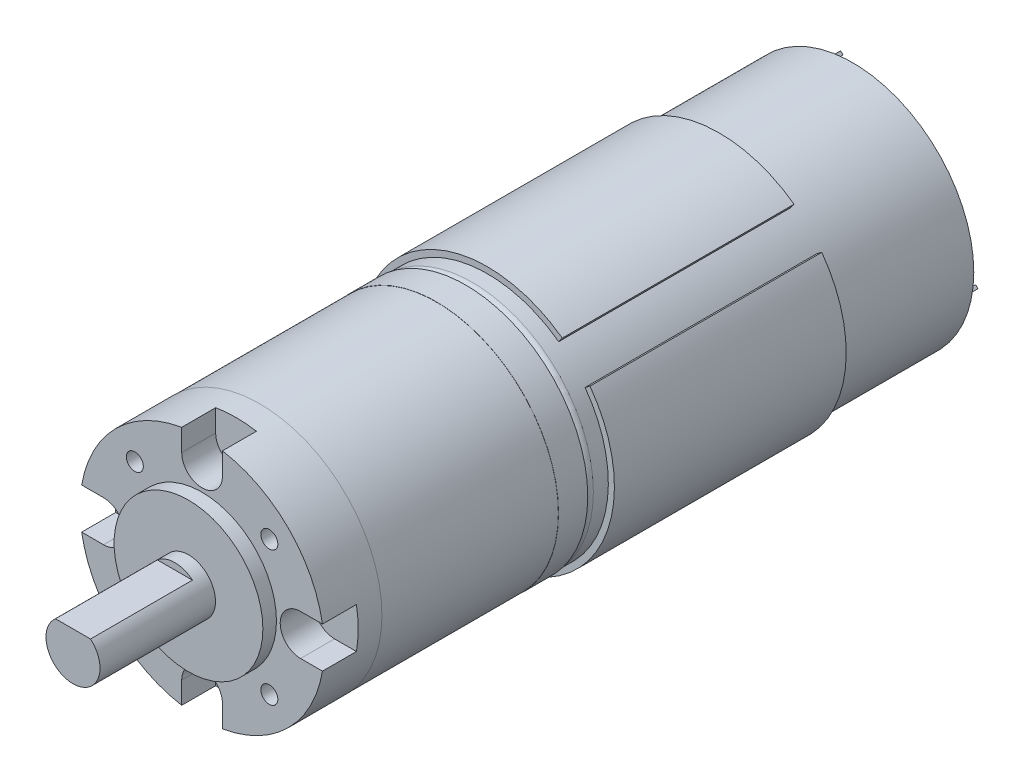
from build123d import *

# Parameters (mm, degrees)
SKETCH1_R                      = 17.975
BOSS_EXTRUDE1_DEPTH            = 8.5
CUT_EXTRUDE1_DEPTH             = 5
SKETCH3_R                      = 10.95
BOSS_EXTRUDE2_DEPTH            = 2
SKETCH4_R                      = 3.975
BOSS_EXTRUDE3_DEPTH            = 17
SKETCH5_W                      = 5.157518784
SKETCH5_H                      = 0.95
CUT_EXTRUDE2_DEPTH             = 15
SKETCH7_W                      = 1.25
SKETCH7_H                      = 8.5
M3X0_5_TAPPED_HOLE1_AT_2_COUNT = 2
M3X0_5_TAPPED_HOLE1_AT_2_PITCH = 19.798989873
M3X0_5_TAPPED_HOLE1_AT_3_COUNT = 2
M3X0_5_TAPPED_HOLE1_AT_3_PITCH = 28
M3X0_5_TAPPED_HOLE1_AT_4_COUNT = 2
M3X0_5_TAPPED_HOLE1_AT_4_PITCH = 19.798989873
SKETCH8_R                      = 17.95
BOSS_EXTRUDE4_DEPTH            = 26
SKETCH9_R                      = 17.975
BOSS_EXTRUDE5_DEPTH            = 4.3
SKETCH10_R                     = 17.8
BOSS_EXTRUDE6_DEPTH            = 57
FILLET1_R                      = 1
SKETCH11_R                     = 5.375
BOSS_EXTRUDE7_DEPTH            = 2.95
BOSS_EXTRUDE8_DEPTH            = 7
BOSS_EXTRUDE8_2_DEPTH          = 7
BOSS_EXTRUDE9_DEPTH            = 34.12


with BuildPart() as part:
    # Sketch1 → Boss-Extrude1 (new body)
    with BuildSketch(Plane.XY):
        Circle(SKETCH1_R)
    extrude(amount=BOSS_EXTRUDE1_DEPTH)

    # Sketch2 → Cut-Extrude1 (cut)
    with BuildSketch(Plane.XY.offset(8.5)):
        with BuildLine():
            Line((-14.5, -3), (-24.5, -3))
            ThreePointArc((-24.5, -3), (-27.5, 0), (-24.5, 3))
            Line((-24.5, 3), (-14.5, 3))
            ThreePointArc((-14.5, 3), (-11.5, 0), (-14.5, -3))
        make_face()
        with BuildLine():
            Line((14.5, -3), (24.5, -3))
            ThreePointArc((24.5, -3), (27.5, 0), (24.5, 3))
            Line((24.5, 3), (14.5, 3))
            ThreePointArc((14.5, 3), (11.5, 0), (14.5, -3))
        make_face()
        with BuildLine():
            Line((-3, 14.5), (-3, 24.5))
            ThreePointArc((-3, 24.5), (0, 27.5), (3, 24.5))
            Line((3, 24.5), (3, 14.5))
            ThreePointArc((3, 14.5), (0, 11.5), (-3, 14.5))
        make_face()
        with BuildLine():
            Line((-3, -14.5), (-3, -24.5))
            ThreePointArc((-3, -24.5), (0, -27.5), (3, -24.5))
            Line((3, -24.5), (3, -14.5))
            ThreePointArc((3, -14.5), (0, -11.5), (-3, -14.5))
        make_face()
    extrude(amount=-CUT_EXTRUDE1_DEPTH, mode=Mode.SUBTRACT)

    # Sketch3 → Boss-Extrude2 (add)
    with BuildSketch(Plane.XY.offset(8.5)):
        Circle(SKETCH3_R)
    extrude(amount=BOSS_EXTRUDE2_DEPTH)

    # Sketch7 → M3x0.5 Tapped Hole1 (revolve, cut)
    with BuildSketch(Plane(origin=(-9.899494937, 9.899494937, 8.5), x_dir=(0, -1, 0), z_dir=(1, 0, 0))):
        with Locations((0.625, 4.25)):
            Rectangle(SKETCH7_W, SKETCH7_H)
    m3x0_5_tapped_hole1 = revolve(axis=Axis((-9.899494937, 9.899494937, 14.85), (0, 0, -1)), mode=Mode.SUBTRACT)

    # M3x0.5 Tapped Hole1 at 2: M3x0.5 Tapped Hole1 ×2
    with Locations(*[(0, -i * M3X0_5_TAPPED_HOLE1_AT_2_PITCH, 0) for i in range(1, M3X0_5_TAPPED_HOLE1_AT_2_COUNT)]):
        add(m3x0_5_tapped_hole1, mode=Mode.SUBTRACT)

    # M3x0.5 Tapped Hole1 at 3: M3x0.5 Tapped Hole1 ×2
    with Locations(*[Vector(0.707106781, -0.707106781, 0) * (i * M3X0_5_TAPPED_HOLE1_AT_3_PITCH) for i in range(1, M3X0_5_TAPPED_HOLE1_AT_3_COUNT)]):
        add(m3x0_5_tapped_hole1, mode=Mode.SUBTRACT)

    # M3x0.5 Tapped Hole1 at 4: M3x0.5 Tapped Hole1 ×2
    with Locations(*[(i * M3X0_5_TAPPED_HOLE1_AT_4_PITCH, 0, 0) for i in range(1, M3X0_5_TAPPED_HOLE1_AT_4_COUNT)]):
        add(m3x0_5_tapped_hole1, mode=Mode.SUBTRACT)


with BuildPart() as body_2:
    # Sketch4 → Boss-Extrude3 (new body)
    with BuildSketch(Plane.XY.offset(10.5)):
        Circle(SKETCH4_R)
    extrude(amount=BOSS_EXTRUDE3_DEPTH)

    # Sketch5 → Cut-Extrude2 (cut)
    with BuildSketch(Plane.XY.offset(27.5)):
        with Locations((0, 3.5)):
            Rectangle(SKETCH5_W, SKETCH5_H)
    extrude(amount=-CUT_EXTRUDE2_DEPTH, mode=Mode.SUBTRACT)


with BuildPart() as body_3:
    # Sketch8 → Boss-Extrude4 (new body)
    with BuildSketch(Plane(origin=(0, 0, 0), x_dir=(-1, 0, 0), z_dir=(0, 0, -1))):
        Circle(SKETCH8_R)
    extrude(amount=BOSS_EXTRUDE4_DEPTH)


with BuildPart() as body_4:
    # Sketch9 → Boss-Extrude5 (new body)
    with BuildSketch(Plane(origin=(0, 0, -26), x_dir=(-1, 0, 0), z_dir=(0, 0, -1))):
        Circle(SKETCH9_R)
    extrude(amount=BOSS_EXTRUDE5_DEPTH)


with BuildPart() as body_5:
    # Sketch10 → Boss-Extrude6 (new body)
    with BuildSketch(Plane(origin=(0, 0, -30.3), x_dir=(-1, 0, 0), z_dir=(0, 0, -1))):
        Circle(SKETCH10_R)
    extrude(amount=BOSS_EXTRUDE6_DEPTH)

    # Fillet1
    fillet1_edges = [body_5.edges().sort_by_distance(p)[0] for p in [
        (17.8, 0, -30.3),
    ]]
    fillet(fillet1_edges, radius=FILLET1_R)

    # Sketch11 → Boss-Extrude7 (add)
    with BuildSketch(Plane.XY.offset(-90.25)):
        Circle(SKETCH11_R)
    extrude(amount=BOSS_EXTRUDE7_DEPTH)


with BuildPart() as body_6:
    # Sketch12 → Boss-Extrude8 (new body)
    with BuildSketch(Plane(origin=(0, 0, -87.3), x_dir=(-1, 0, 0), z_dir=(0, 0, -1))):
        Polygon((8.449926035, 11.066221126), (11.066221126, 8.449926035), (11.419774516, 8.803479426), (8.803479426, 11.419774516), align=None)
    extrude(amount=BOSS_EXTRUDE8_DEPTH)


with BuildPart() as body_7:
    # Sketch12 → Boss-Extrude8 2 (new body)
    with BuildSketch(Plane(origin=(0, 0, -87.3), x_dir=(-1, 0, 0), z_dir=(0, 0, -1))):
        Polygon((-11.419774516, -8.803479426), (-8.803479426, -11.419774516), (-8.449926035, -11.066221126), (-11.066221126, -8.449926035), align=None)
    extrude(amount=BOSS_EXTRUDE8_2_DEPTH)


with BuildPart() as body_8:
    # Sketch13 → Boss-Extrude9 (new body)
    with BuildSketch(Plane.XY.offset(-33.5)):
        with BuildLine():
            Line((10.490839337, 14.379926634), (11.021275034, 15.107001576))
            ThreePointArc((11.021275034, 15.107001576), (-13.222896808, -13.222896808), (15.107001576, 11.021275034))
            Line((15.107001576, 11.021275034), (14.379926634, 10.490839337))
            ThreePointArc((14.379926634, 10.490839337), (-12.586500705, -12.586500705), (10.490839337, 14.379926634))
        make_face()
    extrude(amount=-BOSS_EXTRUDE9_DEPTH)


solid = Compound([part.part, body_2.part, body_3.part, body_4.part, body_5.part, body_6.part, body_7.part, body_8.part])
